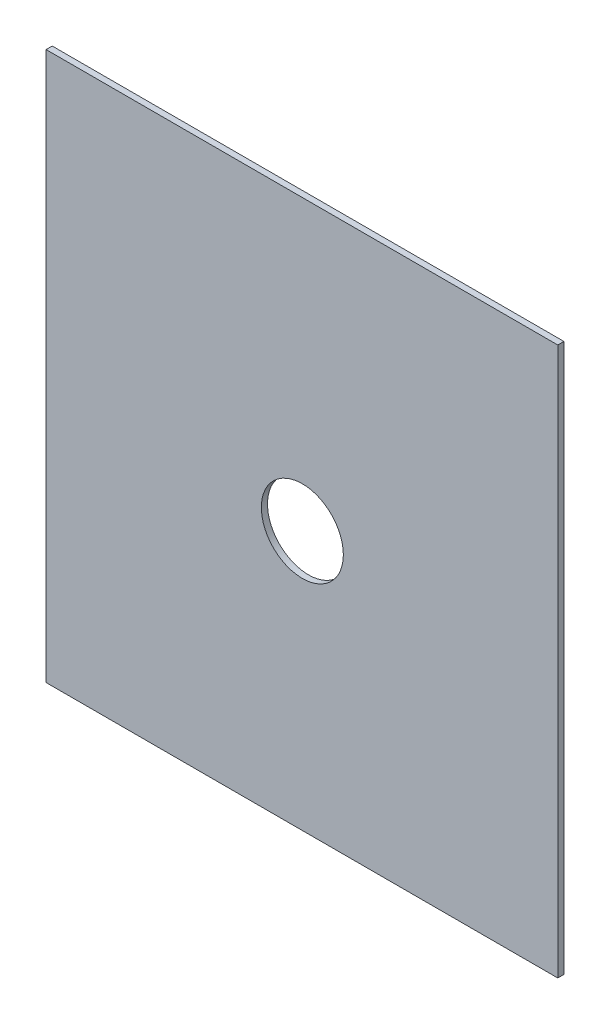
from build123d import *

# Parameters (mm, degrees)
SKETCH1_W           = 249.6
SKETCH1_H           = 267.4
BOSS_EXTRUDE1_DEPTH = 3
SKETCH2_R           = 20
CUT_EXTRUDE1_DEPTH  = 4


with BuildPart() as part:
    # Sketch1 → Boss-Extrude1 (new body)
    with BuildSketch(Plane.XY):
        with Locations((124.8, -133.7)):
            Rectangle(SKETCH1_W, SKETCH1_H)
    extrude(amount=BOSS_EXTRUDE1_DEPTH)

    # Sketch2 → Cut-Extrude1 (cut, through all)
    with BuildSketch(Plane.XY.offset(3)):
        with Locations((125, -140.910978413)):
            Circle(SKETCH2_R)
    extrude(amount=-CUT_EXTRUDE1_DEPTH, mode=Mode.SUBTRACT)


solid = part.part
